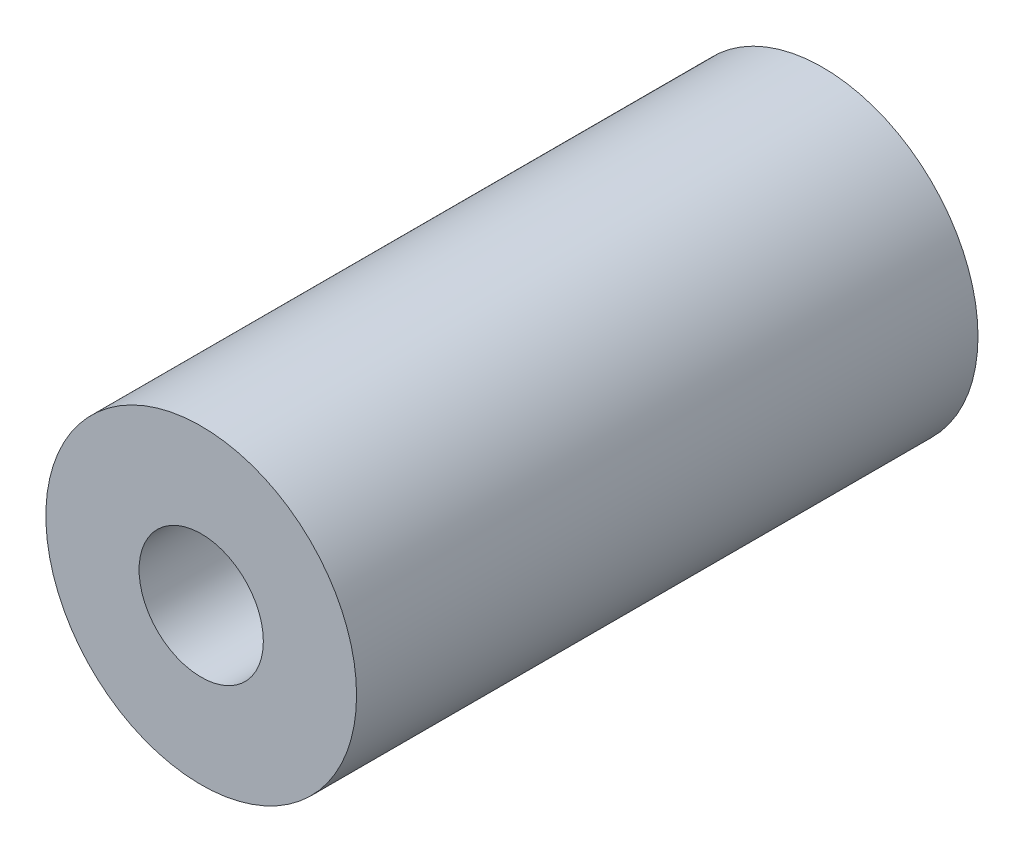
from build123d import *

# Parameters (mm, degrees)
SKETCH1_R           = 7.9375
SKETCH1_R_2         = 3.175
BOSS_EXTRUDE1_DEPTH = 31.75


with BuildPart() as part:
    # Sketch1 → Boss-Extrude1 (new body)
    with BuildSketch(Plane.XY):
        Circle(SKETCH1_R)
        Circle(SKETCH1_R_2, mode=Mode.SUBTRACT)
    extrude(amount=BOSS_EXTRUDE1_DEPTH)


solid = part.part
